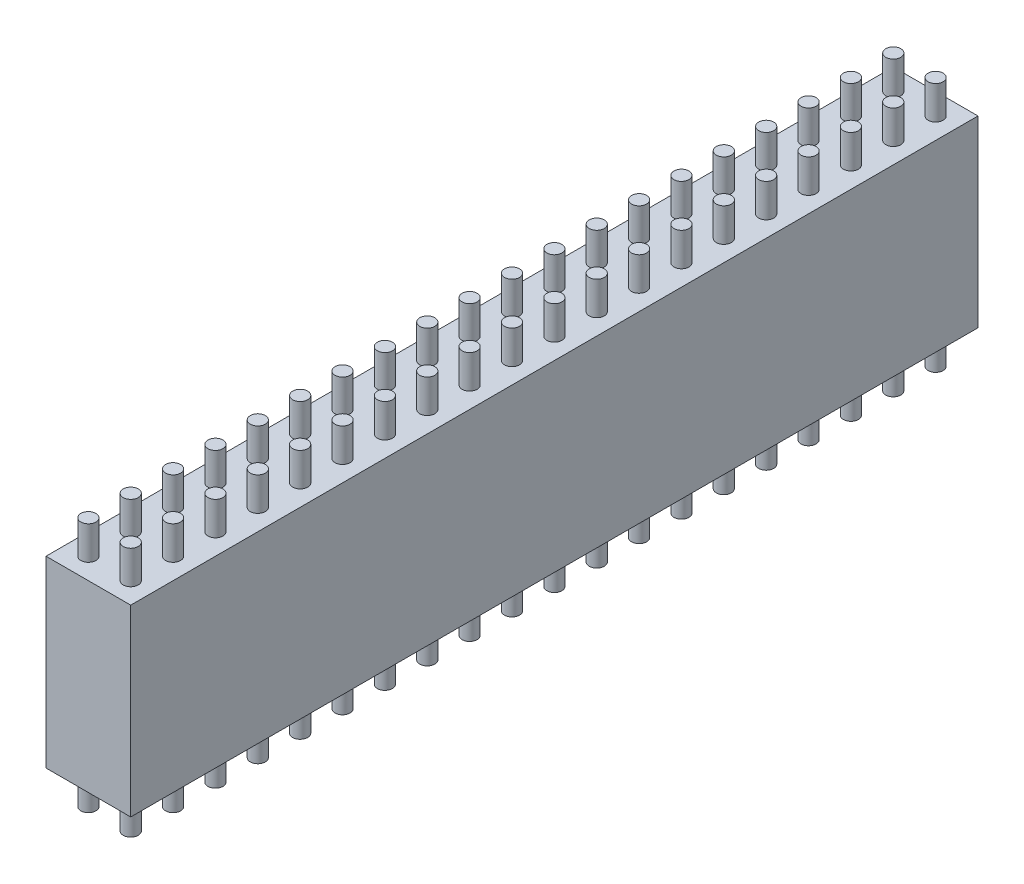
from build123d import *

# Parameters (mm, degrees)
SKIZZE1_W                            = 5.08
SKIZZE1_H                            = 50.8
AUFSATZ_LINEAR_AUSTRAGEN1_DEPTH      = 11
SKIZZE2_R                            = 0.45
AUFSATZ_LINEAR_AUSTRAGEN2_DEPTH      = 2
AUFSATZ_LINEAR_AUSTRAGEN2_DEPTH_BACK = 13


with BuildPart() as part:
    # Skizze1 → Aufsatz-Linear austragen1 (new body)
    with BuildSketch(Plane(origin=(0, 0, 0), x_dir=(1, 0, 0), z_dir=(0, 1, 0))):
        with Locations((2.54, 25.4)):
            Rectangle(SKIZZE1_W, SKIZZE1_H)
    extrude(amount=AUFSATZ_LINEAR_AUSTRAGEN1_DEPTH)

    # Skizze2 → Aufsatz-Linear austragen2 (add, two sides)
    with BuildSketch(Plane(origin=(0, 11, 0), x_dir=(1, 0, 0), z_dir=(0, 1, 0))) as aufsatz_linear_austragen2_sk:
        with Locations((1.27, 1.27)):
            Circle(SKIZZE2_R)
        with Locations((3.81, 1.27)):
            Circle(SKIZZE2_R)
        with Locations((3.81, 3.81)):
            Circle(SKIZZE2_R)
        with Locations((3.81, 6.35)):
            Circle(SKIZZE2_R)
        with Locations((3.81, 8.89)):
            Circle(SKIZZE2_R)
        with Locations((3.81, 11.43)):
            Circle(SKIZZE2_R)
        with Locations((3.81, 13.97)):
            Circle(SKIZZE2_R)
        with Locations((3.81, 16.51)):
            Circle(SKIZZE2_R)
        with Locations((3.81, 19.05)):
            Circle(SKIZZE2_R)
        with Locations((3.81, 21.59)):
            Circle(SKIZZE2_R)
        with Locations((3.81, 24.13)):
            Circle(SKIZZE2_R)
        with Locations((1.27, 3.81)):
            Circle(SKIZZE2_R)
        with Locations((1.27, 6.35)):
            Circle(SKIZZE2_R)
        with Locations((1.27, 8.89)):
            Circle(SKIZZE2_R)
        with Locations((1.27, 11.43)):
            Circle(SKIZZE2_R)
        with Locations((1.27, 13.97)):
            Circle(SKIZZE2_R)
        with Locations((1.27, 16.51)):
            Circle(SKIZZE2_R)
        with Locations((1.27, 19.05)):
            Circle(SKIZZE2_R)
        with Locations((1.27, 21.59)):
            Circle(SKIZZE2_R)
        with Locations((1.27, 24.13)):
            Circle(SKIZZE2_R)
        with Locations((1.27, 26.67)):
            Circle(SKIZZE2_R)
        with Locations((3.81, 26.67)):
            Circle(SKIZZE2_R)
        with Locations((1.27, 29.21)):
            Circle(SKIZZE2_R)
        with Locations((3.81, 29.21)):
            Circle(SKIZZE2_R)
        with Locations((1.27, 31.75)):
            Circle(SKIZZE2_R)
        with Locations((3.81, 31.75)):
            Circle(SKIZZE2_R)
        with Locations((1.27, 34.29)):
            Circle(SKIZZE2_R)
        with Locations((3.81, 34.29)):
            Circle(SKIZZE2_R)
        with Locations((1.27, 36.83)):
            Circle(SKIZZE2_R)
        with Locations((3.81, 36.83)):
            Circle(SKIZZE2_R)
        with Locations((1.27, 39.37)):
            Circle(SKIZZE2_R)
        with Locations((3.81, 39.37)):
            Circle(SKIZZE2_R)
        with Locations((1.27, 41.91)):
            Circle(SKIZZE2_R)
        with Locations((3.81, 41.91)):
            Circle(SKIZZE2_R)
        with Locations((1.27, 44.45)):
            Circle(SKIZZE2_R)
        with Locations((3.81, 44.45)):
            Circle(SKIZZE2_R)
        with Locations((1.27, 46.99)):
            Circle(SKIZZE2_R)
        with Locations((3.81, 46.99)):
            Circle(SKIZZE2_R)
        with Locations((1.27, 49.53)):
            Circle(SKIZZE2_R)
        with Locations((3.81, 49.53)):
            Circle(SKIZZE2_R)
    extrude(amount=AUFSATZ_LINEAR_AUSTRAGEN2_DEPTH)
    extrude(aufsatz_linear_austragen2_sk.sketch, amount=-AUFSATZ_LINEAR_AUSTRAGEN2_DEPTH_BACK)


solid = part.part
